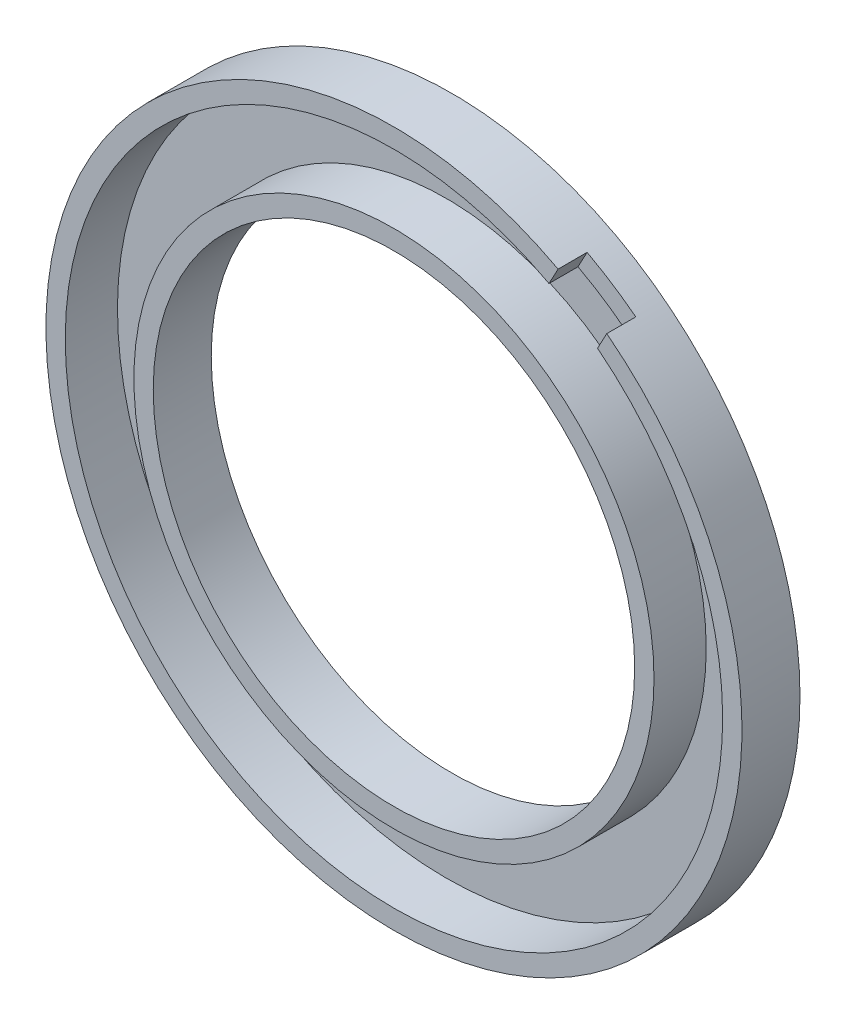
from build123d import *

# Parameters (mm, degrees)
SKETCH1_R             = 36
SKETCH1_R_2           = 34
BOSS_EXTRUDE1_DEPTH   = 6
SKETCH1_R_3           = 26.9
SKETCH1_R_4           = 24.9
BOSS_EXTRUDE1_2_DEPTH = 6
SKETCH1_3_R           = 34
SKETCH1_3_R_2         = 26.9
BOSS_EXTRUDE2_DEPTH   = 0.6
CUT_EXTRUDE1_DEPTH    = 3


with BuildPart() as part:
    # Sketch1 → Boss-Extrude1 (new body)
    with BuildSketch(Plane.XY):
        Circle(SKETCH1_R)
        Circle(SKETCH1_R_2, mode=Mode.SUBTRACT)
    extrude(amount=BOSS_EXTRUDE1_DEPTH)



with BuildPart() as body_2:
    # Sketch1 → Boss-Extrude1 2 (new body)
    with BuildSketch(Plane.XY):
        Circle(SKETCH1_R_3)
        Circle(SKETCH1_R_4, mode=Mode.SUBTRACT)
    extrude(amount=BOSS_EXTRUDE1_2_DEPTH)


with BuildPart() as part_1:
    add(part.part)

    add(body_2.part)  # Boss-Extrude2 merges body 2
    # Sketch1_3 → Boss-Extrude2 (add)
    with BuildSketch(Plane.XY):
        Circle(SKETCH1_3_R)
        Circle(SKETCH1_3_R_2, mode=Mode.SUBTRACT)
    extrude(amount=BOSS_EXTRUDE2_DEPTH)

    # Sketch4 → Cut-Extrude1 (cut)
    with BuildSketch(Plane.XY.offset(6)):
        Polygon((22.015125438, 28.483929714), (21.055768183, 26.695591888), (17.287744391, 26.985727401), (16.035297847, 29.981147793), (16.978550661, 31.744744722), (21.055768183, 32.257714182), align=None)
    extrude(amount=-CUT_EXTRUDE1_DEPTH, mode=Mode.SUBTRACT)


solid = part_1.part
